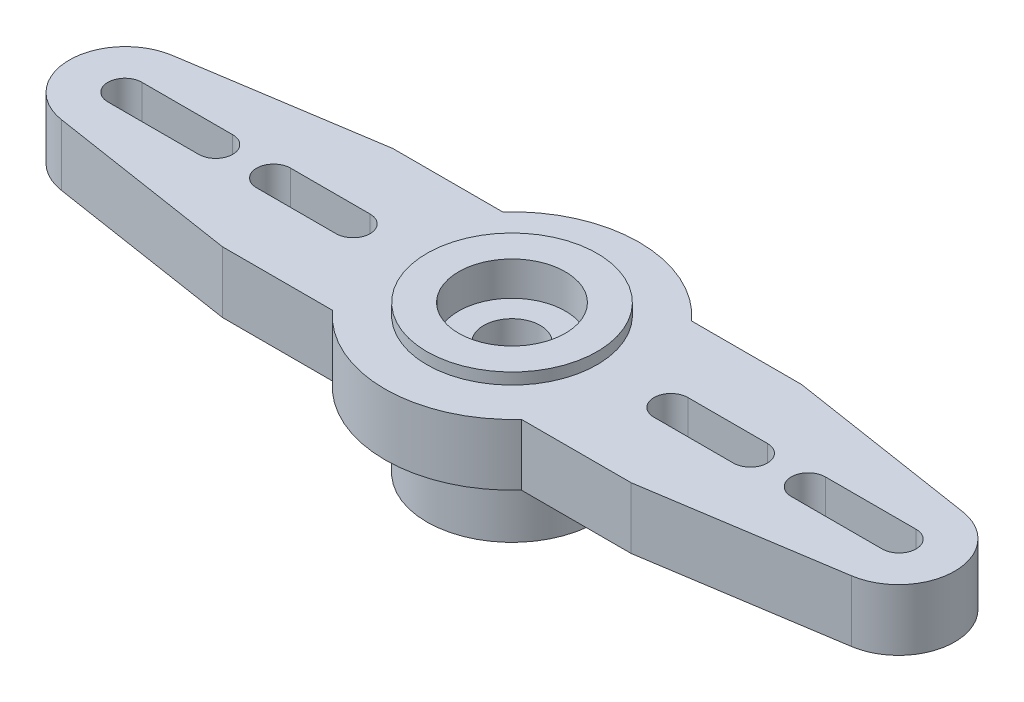
from build123d import *

# Parameters (mm, degrees)
SKETCH2_R               = 3.75
BOSS_EXTRUDE1_DEPTH     = 6.5
SKETCH3_R               = 1.25
CUT_EXTRUDE1_DEPTH      = 1
CUT_EXTRUDE1_DEPTH_BACK = 7.5
SKETCH4_R               = 2.35
CUT_EXTRUDE2_DEPTH      = 1
CUT_EXTRUDE2_DEPTH_BACK = 1.5
SKETCH7_R               = 2.35
CUT_EXTRUDE5_DEPTH      = 3.4
SKETCH8_R               = 3.75
BOSS_EXTRUDE4_DEPTH     = 2.7


with BuildPart() as part:
    # Sketch2 → Boss-Extrude1 (new body)
    with BuildSketch(Plane(origin=(0, 0, 0), x_dir=(1, 0, 0), z_dir=(0, 1, 0))):
        Circle(SKETCH2_R)
    extrude(amount=BOSS_EXTRUDE1_DEPTH)

    # Sketch3 → Cut-Extrude1 (cut, two sides)
    with BuildSketch(Plane(origin=(0, 6.5, 0), x_dir=(1, 0, 0), z_dir=(0, 1, 0))) as cut_extrude1_sk:
        Circle(SKETCH3_R)
    extrude(amount=CUT_EXTRUDE1_DEPTH, mode=Mode.SUBTRACT)
    extrude(cut_extrude1_sk.sketch, amount=-CUT_EXTRUDE1_DEPTH_BACK, mode=Mode.SUBTRACT)

    # Sketch4 → Cut-Extrude2 (cut, two sides)
    with BuildSketch(Plane(origin=(0, 6.5, 0), x_dir=(1, 0, 0), z_dir=(0, 1, 0))) as cut_extrude2_sk:
        Circle(SKETCH4_R)
    extrude(amount=CUT_EXTRUDE2_DEPTH, mode=Mode.SUBTRACT)
    extrude(cut_extrude2_sk.sketch, amount=-CUT_EXTRUDE2_DEPTH_BACK, mode=Mode.SUBTRACT)

    # Sketch7 → Cut-Extrude5 (cut)
    with BuildSketch(Plane.XZ):
        Circle(SKETCH7_R)
    extrude(amount=-CUT_EXTRUDE5_DEPTH, mode=Mode.SUBTRACT)

    # Sketch8 → Boss-Extrude4 (add)
    with BuildSketch(Plane(origin=(0, 6, 0), x_dir=(1, 0, 0), z_dir=(0, 1, 0))):
        with BuildLine():
            Line((-9, -3.75), (-4.159026328, -3.75))
            ThreePointArc((-4.159026328, -3.75), (0, -5.6), (4.159026328, -3.75))
            Line((4.159026328, -3.75), (9, -3.75))
            Line((9, -3.75), (17.404544417, -2.445725053))
            ThreePointArc((17.404544417, -2.445725053), (19.5, 0), (17.404544417, 2.445725053))
            Line((17.404544417, 2.445725053), (9, 3.75))
            Line((9, 3.75), (4.159026328, 3.75))
            ThreePointArc((4.159026328, 3.75), (0, 5.6), (-4.159026328, 3.75))
            Line((-4.159026328, 3.75), (-9, 3.75))
            Line((-9, 3.75), (-17.404544417, 2.445725053))
            ThreePointArc((-17.404544417, 2.445725053), (-19.5, 0), (-17.404544417, -2.445725053))
            Line((-17.404544417, -2.445725053), (-9, -3.75))
        make_face()
        with BuildLine():
            ThreePointArc((-13.05, 0.75), (-12.3, 0), (-13.05, -0.75))
            Line((-13.05, -0.75), (-17.05, -0.75))
            ThreePointArc((-17.05, -0.75), (-17.8, 0), (-17.05, 0.75))
            Line((-17.05, 0.75), (-13.05, 0.75))
        make_face(mode=Mode.SUBTRACT)
        with BuildLine():
            ThreePointArc((-7, 0.75), (-6.25, 0), (-7, -0.75))
            Line((-7, -0.75), (-10.5, -0.75))
            ThreePointArc((-10.5, -0.75), (-11.25, 0), (-10.5, 0.75))
            Line((-10.5, 0.75), (-7, 0.75))
        make_face(mode=Mode.SUBTRACT)
        Circle(SKETCH8_R, mode=Mode.SUBTRACT)
        with BuildLine():
            ThreePointArc((7, -0.75), (6.25, 0), (7, 0.75))
            Line((7, 0.75), (10.5, 0.75))
            ThreePointArc((10.5, 0.75), (11.25, 0), (10.5, -0.75))
            Line((10.5, -0.75), (7, -0.75))
        make_face(mode=Mode.SUBTRACT)
        with BuildLine():
            ThreePointArc((17.05, 0.75), (17.8, 0), (17.05, -0.75))
            Line((17.05, -0.75), (13.05, -0.75))
            ThreePointArc((13.05, -0.75), (12.3, 0), (13.05, 0.75))
            Line((13.05, 0.75), (17.05, 0.75))
        make_face(mode=Mode.SUBTRACT)
    extrude(amount=-BOSS_EXTRUDE4_DEPTH)


solid = part.part
